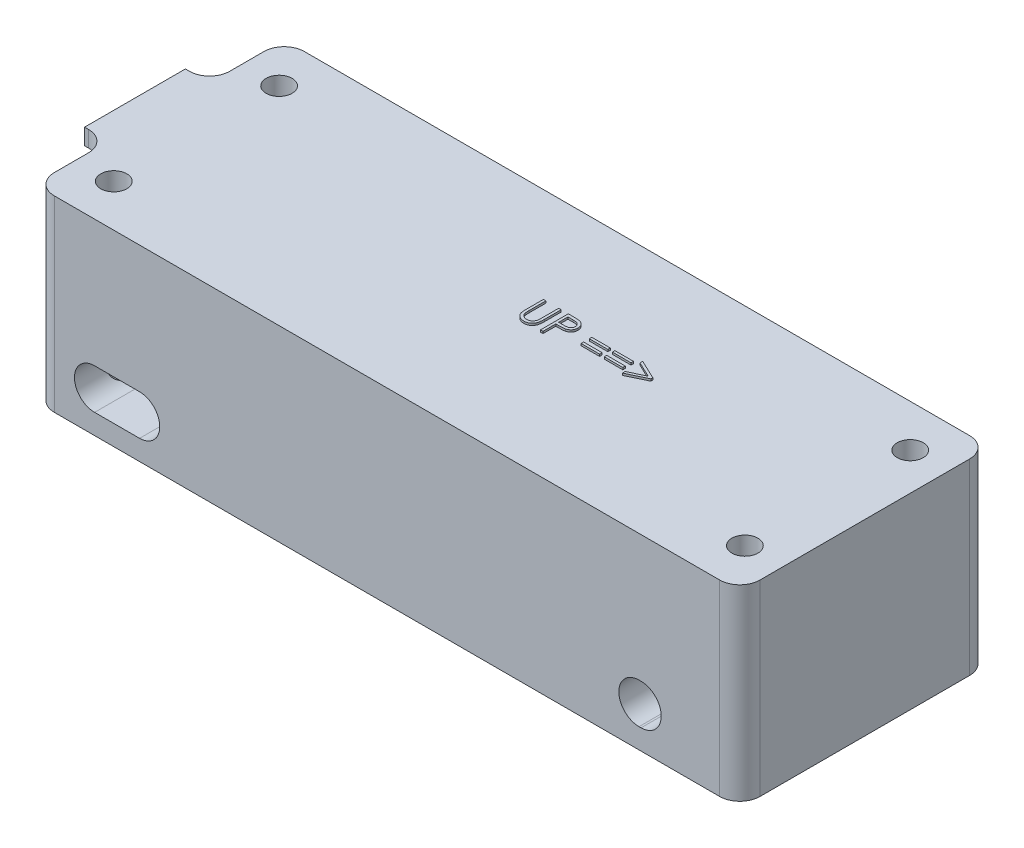
from build123d import *

# Parameters (mm, degrees)
BOSS_EXTRUDE1_DEPTH = 21.59
BOSS_EXTRUDE2_DEPTH = 2.032
SKETCH3_W           = 2.333333334
SKETCH3_H           = 0.314102564
SKETCH3_W_2         = 2.333333333
BOSS_EXTRUDE3_DEPTH = 0.254
SKETCH4_R           = 1.6383
CUT_EXTRUDE1_DEPTH  = 27.94
CUT_EXTRUDE2_DEPTH  = 37.592


with BuildPart() as part:
    # Sketch1 → Boss-Extrude1 (new body)
    with BuildSketch(Plane(origin=(0, 0, 0), x_dir=(1, 0, 0), z_dir=(0, 1, 0))):
        with BuildLine():
            Line((-41.91, 15.748), (41.91, 15.748))
            ThreePointArc((41.91, 15.748), (43.706051224, 15.004051224), (44.45, 13.208))
            Line((44.45, 13.208), (44.45, -13.208))
            ThreePointArc((44.45, -13.208), (43.706051224, -15.004051224), (41.91, -15.748))
            Line((41.91, -15.748), (-41.91, -15.748))
            ThreePointArc((-41.91, -15.748), (-43.706051224, -15.004051224), (-44.45, -13.208))
            Line((-44.45, -13.208), (-44.45, 13.208))
            ThreePointArc((-44.45, 13.208), (-43.706051224, 15.004051224), (-41.91, 15.748))
        make_face()
    extrude(amount=BOSS_EXTRUDE1_DEPTH)

    # Sketch2 → Boss-Extrude2 (add)
    with BuildSketch(Plane(origin=(0, 21.59, 0), x_dir=(1, 0, 0), z_dir=(0, 1, 0))):
        with BuildLine():
            Line((-44.45, -8.89), (-44.45, -13.208))
            ThreePointArc((-44.45, -13.208), (-43.706051224, -15.004051224), (-41.91, -15.748))
            Line((-41.91, -15.748), (41.91, -15.748))
            ThreePointArc((41.91, -15.748), (43.706051224, -15.004051224), (44.45, -13.208))
            Line((44.45, -13.208), (44.45, 13.208))
            ThreePointArc((44.45, 13.208), (43.706051224, 15.004051224), (41.91, 15.748))
            Line((41.91, 15.748), (-41.91, 15.748))
            ThreePointArc((-41.91, 15.748), (-43.706051224, 15.004051224), (-44.45, 13.208))
            Line((-44.45, 13.208), (-44.45, 8.89))
            ThreePointArc((-44.45, 8.89), (-45.193948776, 7.093948776), (-46.99, 6.35))
            Line((-46.99, 6.35), (-47.498, 6.35))
            Line((-47.498, 6.35), (-47.498, -6.35))
            Line((-47.498, -6.35), (-46.99, -6.35))
            ThreePointArc((-46.99, -6.35), (-45.193948776, -7.093948776), (-44.45, -8.89))
        make_face()
    extrude(amount=BOSS_EXTRUDE2_DEPTH)

    # Sketch3 → Boss-Extrude3 (add)
    with BuildSketch(Plane(origin=(0, 23.622, 0), x_dir=(1, 0, 0), z_dir=(0, 1, 0))):
        with BuildLine():
            Line((0.448717949, 3.5), (0.762820513, 3.5))
            Line((0.762820513, 3.5), (0.762820513, 1.402944712))
            add(Edge.make_bspline(
                [(0.762820513, 1.402944712), (0.762773769, 1.373263976), (0.762685064, 1.316939665), (0.763277578, 1.236771364), (0.764936946, 1.165498905), (0.765983106, 1.102847558), (0.768310439, 1.04910481), (0.770208486, 1.0039795), (0.772649043, 0.967685297), (0.775582161, 0.946504371), (0.776842949, 0.93739984)],
                knots=[0, 0, 0, 0, 8.9042e-05, 0.000168973, 0.000240502, 0.000302917, 0.000356945, 0.000401866, 0.000438432, 0.000465999, 0.000465999, 0.000465999, 0.000465999], degree=3))
            add(Edge.make_bspline(
                [(0.776842949, 0.93739984), (0.782020408, 0.904553076), (0.792083594, 0.840710347), (0.817729972, 0.749802065), (0.853547473, 0.667870607), (0.895990515, 0.592359316), (0.951923127, 0.525369956), (1.018926662, 0.463658303), (1.100104431, 0.409686499), (1.190365036, 0.360335687), (1.287650274, 0.320670604), (1.38706154, 0.29067724), (1.487104519, 0.27239834), (1.554080684, 0.270281801), (1.587339744, 0.269230769)],
                knots=[0, 0, 0, 0, 9.971e-05, 0.000193801, 0.000282365, 0.000367504, 0.000452699, 0.000543015, 0.000639862, 0.000744331, 0.000851226, 0.000954377, 0.001055468, 0.001155185, 0.001155185, 0.001155185, 0.001155185], degree=3))
            add(Edge.make_bspline(
                [(1.587339744, 0.269230769), (1.615893484, 0.27030462), (1.672836046, 0.272446118), (1.757442477, 0.285707549), (1.839842585, 0.309608115), (1.920443265, 0.340447873), (1.99599425, 0.381195464), (2.066537692, 0.428266303), (2.129501626, 0.48347718), (2.186959624, 0.544577524), (2.236994559, 0.613517324), (2.280365701, 0.688795462), (2.315891631, 0.771544809), (2.333435156, 0.829699231), (2.342447917, 0.859575321)],
                knots=[0, 0, 0, 0, 8.5678e-05, 0.00017086, 0.000256092, 0.000342674, 0.000429242, 0.000513055, 0.000596556, 0.000679898, 0.000764179, 0.00085149, 0.000940054, 0.001033621, 0.001033621, 0.001033621, 0.001033621], degree=3))
            add(Edge.make_bspline(
                [(2.342447917, 0.859575321), (2.345448042, 0.871923895), (2.35213353, 0.899441495), (2.358380575, 0.945962785), (2.364887101, 1.000852149), (2.369401671, 1.064503962), (2.373802891, 1.136704935), (2.376435964, 1.217831192), (2.377652997, 1.307588153), (2.378015677, 1.370225315), (2.378205128, 1.402944712)],
                knots=[0, 0, 0, 0, 3.81e-05, 8.4902e-05, 0.000140649, 0.000203941, 0.000276279, 0.000357657, 0.000447412, 0.000545571, 0.000545571, 0.000545571, 0.000545571], degree=3))
            Line((2.378205128, 1.402944712), (2.378205128, 3.5))
            Line((2.378205128, 3.5), (2.692307692, 3.5))
            Line((2.692307692, 3.5), (2.692307692, 1.386117788))
            add(Edge.make_bspline(
                [(2.692307692, 1.386117788), (2.692053572, 1.34801941), (2.691557641, 1.273668107), (2.687257064, 1.164716748), (2.680400064, 1.061363766), (2.670711976, 0.96359527), (2.657874973, 0.871761111), (2.643599753, 0.785056342), (2.625420219, 0.70410335), (2.604186818, 0.628270932), (2.57991327, 0.556085419), (2.548472122, 0.487576804), (2.513047622, 0.420662404), (2.471032969, 0.356354295), (2.423821586, 0.294367742), (2.370369906, 0.235078667), (2.312445745, 0.177539621), (2.249086185, 0.123226555), (2.18133566, 0.073417878), (2.109395702, 0.029620107), (2.033818933, -0.007403511), (1.954801806, -0.037879435), (1.872310604, -0.060794034), (1.786343244, -0.07786919), (1.69670405, -0.087571487), (1.635739394, -0.089013418), (1.604867788, -0.08974359)],
                knots=[0, 0, 0, 0, 0.000114291, 0.000223047, 0.000327049, 0.000424998, 0.000517708, 0.000605194, 0.000688542, 0.000766455, 0.0008414, 0.000916717, 0.000992315, 0.001068354, 0.001146882, 0.001225836, 0.001307639, 0.001391671, 0.001475952, 0.001559641, 0.001643989, 0.001728103, 0.001813335, 0.001900511, 0.00199079, 0.002083404, 0.002083404, 0.002083404, 0.002083404], degree=3))
            add(Edge.make_bspline(
                [(1.604867788, -0.08974359), (1.571198686, -0.088958824), (1.505140027, -0.087419118), (1.40780196, -0.078596368), (1.314487763, -0.061977973), (1.224211886, -0.04081803), (1.138203389, -0.011634292), (1.055309945, 0.022463832), (0.976951264, 0.064341093), (0.901856135, 0.110934486), (0.832031379, 0.163359124), (0.767933976, 0.220499298), (0.709458105, 0.281439675), (0.657589409, 0.346840041), (0.611468524, 0.416191748), (0.571738311, 0.489690988), (0.537625067, 0.567309304), (0.5200185, 0.621262504), (0.511117788, 0.64853766)],
                knots=[0, 0, 0, 0, 0.000101022, 0.000198206, 0.000292839, 0.000385177, 0.00047608, 0.000565014, 0.000653769, 0.000742283, 0.000829923, 0.000915339, 0.000999643, 0.001082971, 0.00116542, 0.001249186, 0.001333332, 0.001419362, 0.001419362, 0.001419362, 0.001419362], degree=3))
            add(Edge.make_bspline(
                [(0.511117788, 0.64853766), (0.50594063, 0.667170235), (0.494711259, 0.707584704), (0.482685961, 0.774471192), (0.47257688, 0.85148611), (0.463071321, 0.938634728), (0.457462363, 1.035984595), (0.452544925, 1.143493511), (0.448683306, 1.261291472), (0.448706078, 1.343345988), (0.448717949, 1.386117788)],
                knots=[0, 0, 0, 0, 5.799e-05, 0.000125782, 0.000203619, 0.000291034, 0.000388694, 0.000496078, 0.000613919, 0.000742226, 0.000742226, 0.000742226, 0.000742226], degree=3))
            Line((0.448717949, 1.386117788), (0.448717949, 3.5))
        make_face()
        with BuildLine():
            Line((3.58974359, 3.5), (4.276141827, 3.5))
            add(Edge.make_bspline(
                [(4.276141827, 3.5), (4.323352733, 3.499948104), (4.413810926, 3.499848668), (4.543525982, 3.496833922), (4.661335713, 3.49280723), (4.766986094, 3.487225337), (4.860802192, 3.480628747), (4.942359492, 3.471376708), (5.012299048, 3.461716412), (5.054205498, 3.451895005), (5.073317308, 3.447415865)],
                knots=[0, 0, 0, 0, 0.000141628, 0.000271366, 0.00038923, 0.000495248, 0.00058876, 0.000671296, 0.000741499, 0.00080036, 0.00080036, 0.00080036, 0.00080036], degree=3))
            add(Edge.make_bspline(
                [(5.073317308, 3.447415865), (5.097510841, 3.440793916), (5.145327819, 3.427706054), (5.214228862, 3.40149233), (5.279782707, 3.370410165), (5.342214266, 3.334986225), (5.400756349, 3.293700661), (5.45628239, 3.248227043), (5.50830237, 3.197515475), (5.556523762, 3.142134735), (5.60080856, 3.083014525), (5.638938242, 3.019272295), (5.670865469, 2.951980992), (5.698248741, 2.881187421), (5.717957195, 2.806297097), (5.732804095, 2.727830385), (5.742227723, 2.645795695), (5.743130284, 2.589735827), (5.743589744, 2.561197917)],
                knots=[0, 0, 0, 0, 7.5216e-05, 0.00014866, 0.000220794, 0.000292713, 0.000363707, 0.000435434, 0.000507823, 0.000581364, 0.000655543, 0.000729131, 0.000803767, 0.000878771, 0.000956497, 0.001035702, 0.001118238, 0.001203821, 0.001203821, 0.001203821, 0.001203821], degree=3))
            add(Edge.make_bspline(
                [(5.743589744, 2.561197917), (5.743168319, 2.53242014), (5.742343773, 2.476114476), (5.732447488, 2.393741688), (5.719117296, 2.315023298), (5.698620244, 2.240133847), (5.671774571, 2.169518077), (5.640282518, 2.102096845), (5.602298987, 2.039017173), (5.558654158, 1.980050055), (5.510102563, 1.925140143), (5.456849625, 1.874685348), (5.399110333, 1.82898101), (5.337068184, 1.787924666), (5.270118336, 1.752468387), (5.199276182, 1.720711082), (5.123925966, 1.694040021), (5.071783452, 1.68000996), (5.045272436, 1.672876603)],
                knots=[0, 0, 0, 0, 8.6284e-05, 0.00016882, 0.000248587, 0.000325638, 0.000401297, 0.000474998, 0.000548586, 0.000621785, 0.0006948, 0.0007682, 0.000841564, 0.000915458, 0.000991056, 0.00106858, 0.00114819, 0.001230532, 0.001230532, 0.001230532, 0.001230532], degree=3))
            add(Edge.make_bspline(
                [(5.045272436, 1.672876603), (5.023345102, 1.668213621), (4.975290075, 1.657994427), (4.896147352, 1.64658597), (4.804001966, 1.63684837), (4.698979687, 1.629547232), (4.581174782, 1.623296864), (4.450523524, 1.61832877), (4.306769447, 1.615598916), (4.206498203, 1.615458123), (4.154146635, 1.615384615)],
                knots=[0, 0, 0, 0, 6.7238e-05, 0.000147357, 0.000239727, 0.000345177, 0.000463135, 0.000593636, 0.000737393, 0.000894446, 0.000894446, 0.000894446, 0.000894446], degree=3))
            Line((4.154146635, 1.615384615), (3.903846154, 1.615384615))
            Line((3.903846154, 1.615384615), (3.903846154, 0))
            Line((3.903846154, 0), (3.58974359, 0))
            Line((3.58974359, 0), (3.58974359, 3.5))
        make_face()
        with BuildLine():
            Line((3.903846154, 3.141025641), (3.903846154, 1.974358974))
            Line((3.903846154, 1.974358974), (4.516626603, 1.966646635))
            add(Edge.make_bspline(
                [(4.516626603, 1.966646635), (4.546546528, 1.966631171), (4.604306328, 1.966601319), (4.687742552, 1.970586542), (4.765151839, 1.975187075), (4.836296414, 1.981922998), (4.901208349, 1.991444256), (4.959995878, 2.001055994), (5.01220316, 2.014961356), (5.073302362, 2.033684426), (5.14138571, 2.065617041), (5.215453258, 2.111966931), (5.278223845, 2.17104764), (5.332542141, 2.237475471), (5.375648019, 2.3113746), (5.407204012, 2.390443537), (5.425745169, 2.473871387), (5.428231363, 2.530959525), (5.429487179, 2.559795673)],
                knots=[0, 0, 0, 0, 8.9746e-05, 0.000173253, 0.000250533, 0.00032239, 0.000387534, 0.00044736, 0.000500926, 0.000549486, 0.000638903, 0.000725641, 0.000810488, 0.000896226, 0.000982324, 0.00106604, 0.001150757, 0.001237226, 0.001237226, 0.001237226, 0.001237226], degree=3))
            add(Edge.make_bspline(
                [(5.429487179, 2.559795673), (5.428224533, 2.587934187), (5.425714548, 2.643870069), (5.407058685, 2.725848829), (5.375709371, 2.804084534), (5.332252776, 2.877057619), (5.279511647, 2.943246423), (5.218212303, 3.00074355), (5.148499042, 3.046965253), (5.083650811, 3.076798534), (5.026049625, 3.09501381), (4.976017665, 3.10775865), (4.919526991, 3.117934257), (4.856559211, 3.126173759), (4.787602377, 3.133227221), (4.712064062, 3.138013198), (4.630230419, 3.140814654), (4.573419848, 3.140953609), (4.543970353, 3.141025641)],
                knots=[0, 0, 0, 0, 8.4371e-05, 0.000167719, 0.000250783, 0.000336277, 0.000421575, 0.000503926, 0.000587348, 0.000671427, 0.000717102, 0.000768457, 0.000826213, 0.000889178, 0.000958942, 0.001034123, 0.001116202, 0.001204546, 0.001204546, 0.001204546, 0.001204546], degree=3))
            Line((4.543970353, 3.141025641), (3.903846154, 3.141025641))
        make_face(mode=Mode.SUBTRACT)
        with Locations((8.794871795, 2.266025641)):
            Rectangle(SKETCH3_W, SKETCH3_H)
        with Locations((8.794871795, 1.233974359)):
            Rectangle(SKETCH3_W, SKETCH3_H)
        with Locations((11.711538462, 2.266025641)):
            Rectangle(SKETCH3_W_2, SKETCH3_H)
        with Locations((11.711538462, 1.233974359)):
            Rectangle(SKETCH3_W_2, SKETCH3_H)
        Polygon((13.461538462, 0.790164263), (15.426081731, 1.727564103), (13.461538462, 2.664963942), (13.461538462, 3.006410256), (15.884615385, 1.850260417), (15.884615385, 1.604867788), (13.461538462, 0.448717949), align=None)
    extrude(amount=BOSS_EXTRUDE3_DEPTH)

    # Sketch4 → Cut-Extrude1 (cut)
    with BuildSketch(Plane.XZ):
        with Locations((-39.751, 10.414)):
            Circle(SKETCH4_R)
        with Locations((39.751, 10.414)):
            Circle(SKETCH4_R)
        with Locations((39.751, -10.414)):
            Circle(SKETCH4_R)
        with Locations((-39.751, -10.414)):
            Circle(SKETCH4_R)
    extrude(amount=-CUT_EXTRUDE1_DEPTH, mode=Mode.SUBTRACT)

    # Sketch6 → Cut-Extrude2 (cut)
    with BuildSketch(Plane.XY.offset(15.748)):
        with BuildLine():
            Line((-36.83, 7.62), (-31.1658, 7.62))
            ThreePointArc((-31.1658, 7.62), (-28.6258, 5.08), (-31.1658, 2.54))
            Line((-31.1658, 2.54), (-36.83, 2.54))
            ThreePointArc((-36.83, 2.54), (-39.37, 5.08), (-36.83, 7.62))
        make_face()
        with BuildLine():
            Line((31.75, 7.62), (32.004, 7.62))
            ThreePointArc((32.004, 7.62), (34.544, 5.08), (32.004, 2.54))
            Line((32.004, 2.54), (31.75, 2.54))
            ThreePointArc((31.75, 2.54), (29.21, 5.08), (31.75, 7.62))
        make_face()
    extrude(amount=-CUT_EXTRUDE2_DEPTH, mode=Mode.SUBTRACT)


solid = part.part
